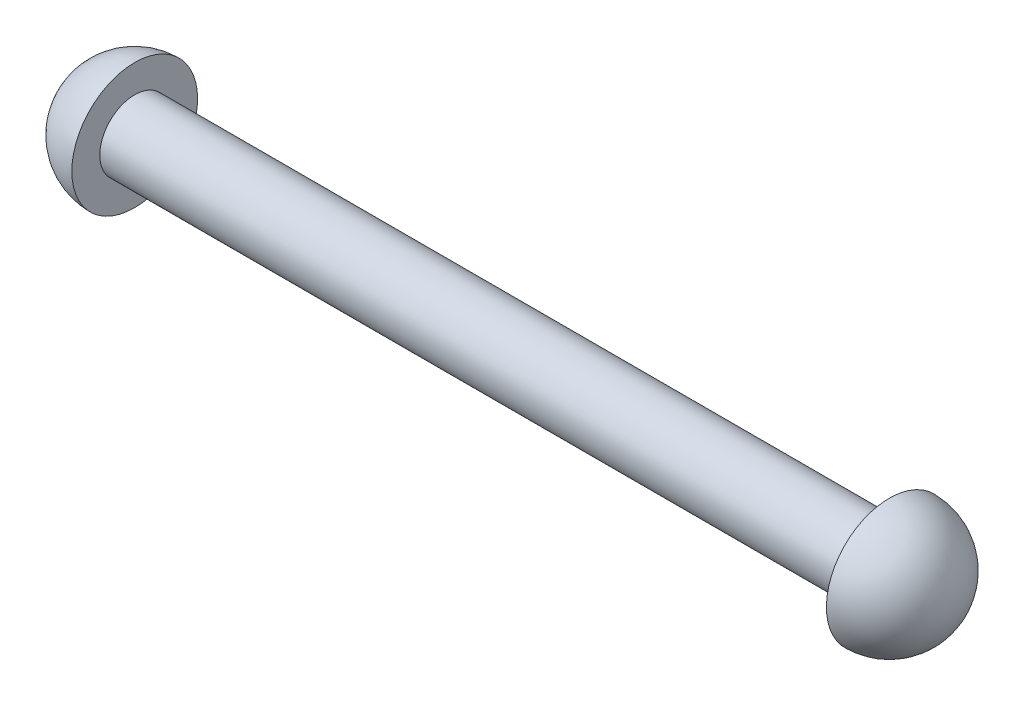
from build123d import *


with BuildPart() as part:
    # Sketch1 → Revolve1 (revolve)
    with BuildSketch(Plane.XY):
        with BuildLine():
            Line((5.715, 5.715), (5.715, 3.175))
            Line((5.715, 3.175), (74.295, 3.175))
            Line((74.295, 3.175), (74.295, 5.715))
            ThreePointArc((74.295, 5.715), (78.336115254, 4.041115254), (80.01, 0))
            Line((80.01, 0), (0, 0))
            ThreePointArc((0, 0), (1.673884746, 4.041115254), (5.715, 5.715))
        make_face()
    revolve(axis=Axis((0, 0, 0), (1, 0, 0)))


solid = part.part
